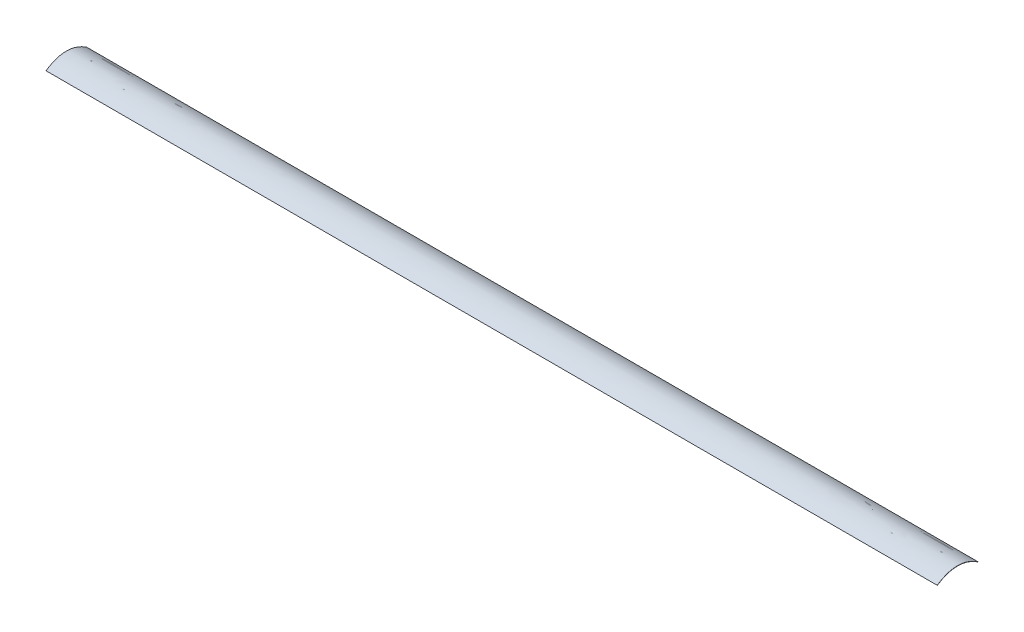
from build123d import *

# Parameters (mm, degrees)
BOSS_EXTRUDE1_DEPTH = 165.1


with BuildPart() as part:
    # Sketch1 → Boss-Extrude1 (new body, symmetric)
    with BuildSketch(Plane(origin=(0, 0, 0), x_dir=(0, 0, -1), z_dir=(1, 0, 0))):
        with BuildLine():
            Line((7.55, 0), (7.45, 0))
            add(Edge.make_bspline(
                [(-7.45, 0), (0, 4.9), (7.45, 0)],
                knots=[0, 0, 0, 1, 1, 1], degree=2))
            Line((-7.45, 0), (-7.55, 0))
            add(Edge.make_bspline(
                [(7.55, 0), (0, 5.1), (-7.55, 0)],
                knots=[0, 0, 0, 1, 1, 1], degree=2))
        make_face()
    extrude(amount=BOSS_EXTRUDE1_DEPTH, both=True)


solid = part.part
